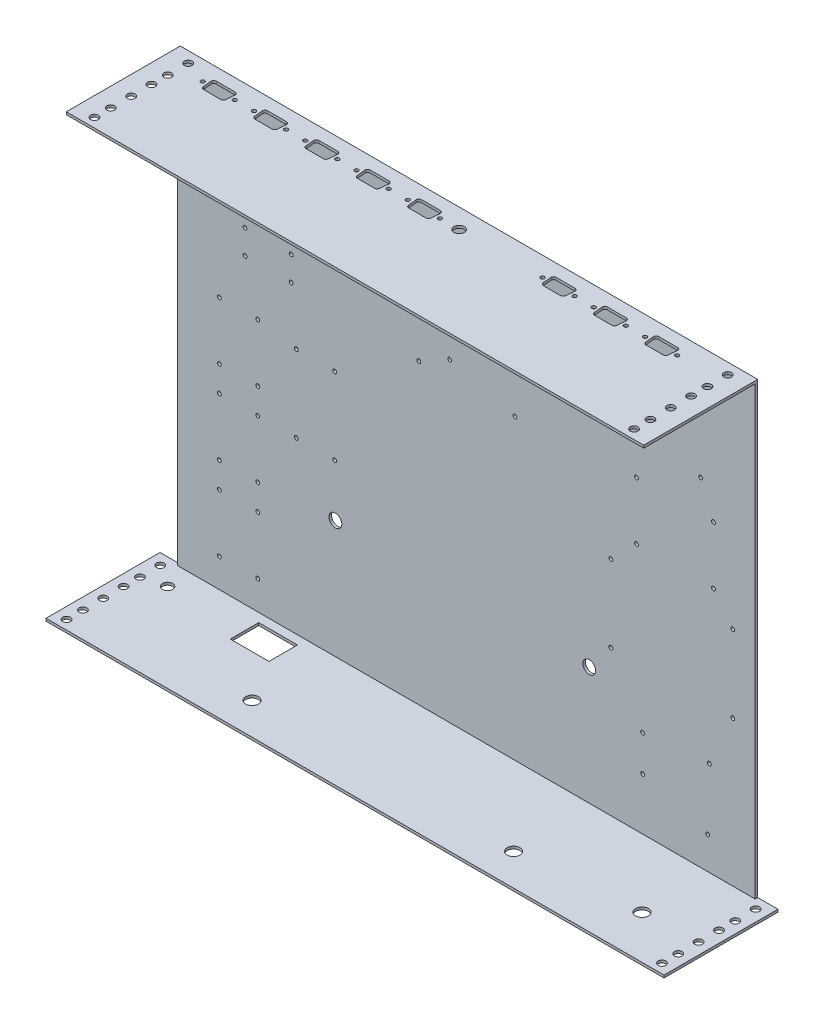
from build123d import *

# Parameters (mm, degrees)
SKETCH1_W           = 450.4
SKETCH1_H           = 352
BOSS_EXTRUDE1_DEPTH = 2
SKETCH4_W           = 482
SKETCH4_H           = 88.9
SKETCH4_W_2         = 9.5
SKETCH4_H_2         = 9.5
BOSS_EXTRUDE4_DEPTH = 2
CUT_EXTRUDE2_REACH  = 354
SKETCH5_W           = 15.8
SKETCH5_H           = 88.9
CUT_EXTRUDE3_REACH  = 354
SKETCH6_W           = 9.5
SKETCH6_H           = 9.5
CUT_EXTRUDE4_REACH  = 4
SKETCH9_R           = 5
CUT_EXTRUDE5_REACH  = 354
SKETCH11_R          = 5
SKETCH12_R          = 1.5
CUT_EXTRUDE6_DEPTH  = 30
SKETCH15_R          = 1.499345427
SKETCH15_R_2        = 1.5
CUT_EXTRUDE7_DEPTH  = 2
SKETCH16_R          = 1.5
SKETCH16_R_2        = 4
CUT_EXTRUDE9_DEPTH  = 2
CUT_EXTRUDE10_REACH = 354
SKETCH17_R          = 4
SKETCH17_R_2        = 5
SKETCH17_W          = 30.2
SKETCH17_H          = 22.2
SKETCH18_W          = 9.5
SKETCH18_H          = 9.5
SKETCH18_R          = 3
BOSS_EXTRUDE5_DEPTH = 2
SKETCH20_W          = 9.5
SKETCH20_H          = 9.5
SKETCH20_R          = 3
BOSS_EXTRUDE6_DEPTH = 2


with BuildPart() as part:
    # Sketch1 → Boss-Extrude1 (new body)
    with BuildSketch(Plane.XY):
        Rectangle(SKETCH1_W, SKETCH1_H)
    extrude(amount=BOSS_EXTRUDE1_DEPTH)

    # Sketch4 → Boss-Extrude4 (add)
    with BuildSketch(Plane.XZ.offset(176)):
        with Locations((0, 44.45)):
            Rectangle(SKETCH4_W, SKETCH4_H)
        with Locations((-232.2, 68.95)):
            Rectangle(SKETCH4_W_2, SKETCH4_H_2, mode=Mode.SUBTRACT)
        with Locations((-232.2, 81.65)):
            Rectangle(SKETCH4_W_2, SKETCH4_H_2, mode=Mode.SUBTRACT)
        with Locations((232.2, 68.95)):
            Rectangle(SKETCH4_W_2, SKETCH4_H_2, mode=Mode.SUBTRACT)
        with Locations((232.2, 81.65)):
            Rectangle(SKETCH4_W_2, SKETCH4_H_2, mode=Mode.SUBTRACT)
        with Locations((-232.2, 53.07)):
            Rectangle(SKETCH4_W_2, SKETCH4_H_2, mode=Mode.SUBTRACT)
        with Locations((232.2, 53.07)):
            Rectangle(SKETCH4_W_2, SKETCH4_H_2, mode=Mode.SUBTRACT)
        with Locations((-232.2, 37.19)):
            Rectangle(SKETCH4_W_2, SKETCH4_H_2, mode=Mode.SUBTRACT)
        with Locations((-232.2, 24.49)):
            Rectangle(SKETCH4_W_2, SKETCH4_H_2, mode=Mode.SUBTRACT)
        with Locations((-232.2, 8.61)):
            Rectangle(SKETCH4_W_2, SKETCH4_H_2, mode=Mode.SUBTRACT)
        with Locations((232.2, 37.19)):
            Rectangle(SKETCH4_W_2, SKETCH4_H_2, mode=Mode.SUBTRACT)
        with Locations((232.2, 24.49)):
            Rectangle(SKETCH4_W_2, SKETCH4_H_2, mode=Mode.SUBTRACT)
        with Locations((232.2, 8.61)):
            Rectangle(SKETCH4_W_2, SKETCH4_H_2, mode=Mode.SUBTRACT)
    boss_extrude4 = extrude(amount=-BOSS_EXTRUDE4_DEPTH)

    # Mirror1: Boss-Extrude4 across plane
    add(boss_extrude4.mirror(Plane.ZX))

    # Sketch5 → Cut-Extrude2 (cut, up to next)
    with BuildSketch(Plane(origin=(0, 176, 0), x_dir=(1, 0, 0), z_dir=(0, 1, 0)), mode=Mode.PRIVATE) as cut_extrude2_sk1:
        with Locations((-233.1, -44.45)):
            Rectangle(SKETCH5_W, SKETCH5_H)
    cut_extrude2_tool1 = extrude(cut_extrude2_sk1.sketch, amount=-CUT_EXTRUDE2_REACH, mode=Mode.PRIVATE) & part.part
    add(cut_extrude2_tool1.solids().sort_by_distance((-233.1, 176, 44.45))[0], mode=Mode.SUBTRACT)
    # Sketch5 → Cut-Extrude2 (cut, up to next)
    with BuildSketch(Plane(origin=(0, 176, 0), x_dir=(1, 0, 0), z_dir=(0, 1, 0)), mode=Mode.PRIVATE) as cut_extrude2_sk2:
        with Locations((233.1, -44.45)):
            Rectangle(SKETCH5_W, SKETCH5_H)
    cut_extrude2_tool2 = extrude(cut_extrude2_sk2.sketch, amount=-CUT_EXTRUDE2_REACH, mode=Mode.PRIVATE) & part.part
    add(cut_extrude2_tool2.solids().sort_by_distance((233.1, 176, 44.45))[0], mode=Mode.SUBTRACT)

    # Sketch6 → Cut-Extrude3 (cut, up to next)
    with BuildSketch(Plane(origin=(0, 176, 0), x_dir=(1, 0, 0), z_dir=(0, 1, 0)), mode=Mode.PRIVATE) as cut_extrude3_sk1:
        with Locations((-210.45, -8.61)):
            Rectangle(SKETCH6_W, SKETCH6_H)
    cut_extrude3_tool1 = extrude(cut_extrude3_sk1.sketch, amount=-CUT_EXTRUDE3_REACH, mode=Mode.PRIVATE) & part.part
    add(cut_extrude3_tool1.solids().sort_by_distance((-210.45, 176, 8.61))[0], mode=Mode.SUBTRACT)
    # Sketch6 → Cut-Extrude3 (cut, up to next)
    with BuildSketch(Plane(origin=(0, 176, 0), x_dir=(1, 0, 0), z_dir=(0, 1, 0)), mode=Mode.PRIVATE) as cut_extrude3_sk2:
        with Locations((-210.45, -24.49)):
            Rectangle(SKETCH6_W, SKETCH6_H)
    cut_extrude3_tool2 = extrude(cut_extrude3_sk2.sketch, amount=-CUT_EXTRUDE3_REACH, mode=Mode.PRIVATE) & part.part
    add(cut_extrude3_tool2.solids().sort_by_distance((-210.45, 176, 24.49))[0], mode=Mode.SUBTRACT)
    # Sketch6 → Cut-Extrude3 (cut, up to next)
    with BuildSketch(Plane(origin=(0, 176, 0), x_dir=(1, 0, 0), z_dir=(0, 1, 0)), mode=Mode.PRIVATE) as cut_extrude3_sk3:
        with Locations((210.45, -8.61)):
            Rectangle(SKETCH6_W, SKETCH6_H)
    cut_extrude3_tool3 = extrude(cut_extrude3_sk3.sketch, amount=-CUT_EXTRUDE3_REACH, mode=Mode.PRIVATE) & part.part
    add(cut_extrude3_tool3.solids().sort_by_distance((210.45, 176, 8.61))[0], mode=Mode.SUBTRACT)
    # Sketch6 → Cut-Extrude3 (cut, up to next)
    with BuildSketch(Plane(origin=(0, 176, 0), x_dir=(1, 0, 0), z_dir=(0, 1, 0)), mode=Mode.PRIVATE) as cut_extrude3_sk4:
        with Locations((210.45, -24.49)):
            Rectangle(SKETCH6_W, SKETCH6_H)
    cut_extrude3_tool4 = extrude(cut_extrude3_sk4.sketch, amount=-CUT_EXTRUDE3_REACH, mode=Mode.PRIVATE) & part.part
    add(cut_extrude3_tool4.solids().sort_by_distance((210.45, 176, 24.49))[0], mode=Mode.SUBTRACT)
    # Sketch6 → Cut-Extrude3 (cut, up to next)
    with BuildSketch(Plane(origin=(0, 176, 0), x_dir=(1, 0, 0), z_dir=(0, 1, 0)), mode=Mode.PRIVATE) as cut_extrude3_sk5:
        with Locations((-210.45, -81.65)):
            Rectangle(SKETCH6_W, SKETCH6_H)
    cut_extrude3_tool5 = extrude(cut_extrude3_sk5.sketch, amount=-CUT_EXTRUDE3_REACH, mode=Mode.PRIVATE) & part.part
    add(cut_extrude3_tool5.solids().sort_by_distance((-210.45, 176, 81.65))[0], mode=Mode.SUBTRACT)
    # Sketch6 → Cut-Extrude3 (cut, up to next)
    with BuildSketch(Plane(origin=(0, 176, 0), x_dir=(1, 0, 0), z_dir=(0, 1, 0)), mode=Mode.PRIVATE) as cut_extrude3_sk6:
        with Locations((-210.45, -37.19)):
            Rectangle(SKETCH6_W, SKETCH6_H)
    cut_extrude3_tool6 = extrude(cut_extrude3_sk6.sketch, amount=-CUT_EXTRUDE3_REACH, mode=Mode.PRIVATE) & part.part
    add(cut_extrude3_tool6.solids().sort_by_distance((-210.45, 176, 37.19))[0], mode=Mode.SUBTRACT)
    # Sketch6 → Cut-Extrude3 (cut, up to next)
    with BuildSketch(Plane(origin=(0, 176, 0), x_dir=(1, 0, 0), z_dir=(0, 1, 0)), mode=Mode.PRIVATE) as cut_extrude3_sk7:
        with Locations((210.45, -37.19)):
            Rectangle(SKETCH6_W, SKETCH6_H)
    cut_extrude3_tool7 = extrude(cut_extrude3_sk7.sketch, amount=-CUT_EXTRUDE3_REACH, mode=Mode.PRIVATE) & part.part
    add(cut_extrude3_tool7.solids().sort_by_distance((210.45, 176, 37.19))[0], mode=Mode.SUBTRACT)
    # Sketch6 → Cut-Extrude3 (cut, up to next)
    with BuildSketch(Plane(origin=(0, 176, 0), x_dir=(1, 0, 0), z_dir=(0, 1, 0)), mode=Mode.PRIVATE) as cut_extrude3_sk8:
        with Locations((-210.45, -68.95)):
            Rectangle(SKETCH6_W, SKETCH6_H)
    cut_extrude3_tool8 = extrude(cut_extrude3_sk8.sketch, amount=-CUT_EXTRUDE3_REACH, mode=Mode.PRIVATE) & part.part
    add(cut_extrude3_tool8.solids().sort_by_distance((-210.45, 176, 68.95))[0], mode=Mode.SUBTRACT)
    # Sketch6 → Cut-Extrude3 (cut, up to next)
    with BuildSketch(Plane(origin=(0, 176, 0), x_dir=(1, 0, 0), z_dir=(0, 1, 0)), mode=Mode.PRIVATE) as cut_extrude3_sk9:
        with Locations((-210.45, -53.07)):
            Rectangle(SKETCH6_W, SKETCH6_H)
    cut_extrude3_tool9 = extrude(cut_extrude3_sk9.sketch, amount=-CUT_EXTRUDE3_REACH, mode=Mode.PRIVATE) & part.part
    add(cut_extrude3_tool9.solids().sort_by_distance((-210.45, 176, 53.07))[0], mode=Mode.SUBTRACT)
    # Sketch6 → Cut-Extrude3 (cut, up to next)
    with BuildSketch(Plane(origin=(0, 176, 0), x_dir=(1, 0, 0), z_dir=(0, 1, 0)), mode=Mode.PRIVATE) as cut_extrude3_sk10:
        with Locations((210.45, -53.07)):
            Rectangle(SKETCH6_W, SKETCH6_H)
    cut_extrude3_tool10 = extrude(cut_extrude3_sk10.sketch, amount=-CUT_EXTRUDE3_REACH, mode=Mode.PRIVATE) & part.part
    add(cut_extrude3_tool10.solids().sort_by_distance((210.45, 176, 53.07))[0], mode=Mode.SUBTRACT)
    # Sketch6 → Cut-Extrude3 (cut, up to next)
    with BuildSketch(Plane(origin=(0, 176, 0), x_dir=(1, 0, 0), z_dir=(0, 1, 0)), mode=Mode.PRIVATE) as cut_extrude3_sk11:
        with Locations((210.45, -68.95)):
            Rectangle(SKETCH6_W, SKETCH6_H)
    cut_extrude3_tool11 = extrude(cut_extrude3_sk11.sketch, amount=-CUT_EXTRUDE3_REACH, mode=Mode.PRIVATE) & part.part
    add(cut_extrude3_tool11.solids().sort_by_distance((210.45, 176, 68.95))[0], mode=Mode.SUBTRACT)
    # Sketch6 → Cut-Extrude3 (cut, up to next)
    with BuildSketch(Plane(origin=(0, 176, 0), x_dir=(1, 0, 0), z_dir=(0, 1, 0)), mode=Mode.PRIVATE) as cut_extrude3_sk12:
        with Locations((210.45, -81.65)):
            Rectangle(SKETCH6_W, SKETCH6_H)
    cut_extrude3_tool12 = extrude(cut_extrude3_sk12.sketch, amount=-CUT_EXTRUDE3_REACH, mode=Mode.PRIVATE) & part.part
    add(cut_extrude3_tool12.solids().sort_by_distance((210.45, 176, 81.65))[0], mode=Mode.SUBTRACT)

    # Sketch9 → Cut-Extrude4 (cut, up to next)
    with BuildSketch(Plane.XY.offset(2), mode=Mode.PRIVATE) as cut_extrude4_sk1:
        with Locations((-102.2, -82)):
            Circle(SKETCH9_R)
    cut_extrude4_tool1 = extrude(cut_extrude4_sk1.sketch, amount=-CUT_EXTRUDE4_REACH, mode=Mode.PRIVATE) & part.part
    add(cut_extrude4_tool1.solids().sort_by_distance((-102.2, -82, 2))[0], mode=Mode.SUBTRACT)
    # Sketch9 → Cut-Extrude4 (cut, up to next)
    with BuildSketch(Plane.XY.offset(2), mode=Mode.PRIVATE) as cut_extrude4_sk2:
        with Locations((95.8, -82)):
            Circle(SKETCH9_R)
    cut_extrude4_tool2 = extrude(cut_extrude4_sk2.sketch, amount=-CUT_EXTRUDE4_REACH, mode=Mode.PRIVATE) & part.part
    add(cut_extrude4_tool2.solids().sort_by_distance((95.8, -82, 2))[0], mode=Mode.SUBTRACT)

    # Sketch11 → Cut-Extrude5 (cut, up to next)
    with BuildSketch(Plane.XZ.offset(176), mode=Mode.PRIVATE) as cut_extrude5_sk1:
        with Locations((-105.2, 64)):
            Circle(SKETCH11_R)
    cut_extrude5_tool1 = extrude(cut_extrude5_sk1.sketch, amount=-CUT_EXTRUDE5_REACH, mode=Mode.PRIVATE) & part.part
    add(cut_extrude5_tool1.solids().sort_by_distance((-105.2, -176, 64))[0], mode=Mode.SUBTRACT)
    # Sketch11 → Cut-Extrude5 (cut, up to next)
    with BuildSketch(Plane.XZ.offset(176), mode=Mode.PRIVATE) as cut_extrude5_sk2:
        with Locations((98.8, 64)):
            Circle(SKETCH11_R)
    cut_extrude5_tool2 = extrude(cut_extrude5_sk2.sketch, amount=-CUT_EXTRUDE5_REACH, mode=Mode.PRIVATE) & part.part
    add(cut_extrude5_tool2.solids().sort_by_distance((98.8, -176, 64))[0], mode=Mode.SUBTRACT)

    # Sketch12 → Cut-Extrude6 (cut)
    with BuildSketch(Plane.XY.offset(2)):
        with Locations((-192.7, -151.5)):
            Circle(SKETCH12_R)
        with Locations((-162.7, -151.5)):
            Circle(SKETCH12_R)
        with Locations((-192.7, -86.5)):
            Circle(SKETCH12_R)
        with Locations((-162.7, -86.5)):
            Circle(SKETCH12_R)
        with Locations((-192.7, -41.5)):
            Circle(SKETCH12_R)
        with Locations((-162.7, -41.5)):
            Circle(SKETCH12_R)
        with Locations((-192.7, -21.5)):
            Circle(SKETCH12_R)
        with Locations((-192.7, -106.5)):
            Circle(SKETCH12_R)
        with Locations((-162.7, -106.5)):
            Circle(SKETCH12_R)
        with Locations((-162.7, -21.5)):
            Circle(SKETCH12_R)
        with Locations((-132.7, -41.5)):
            Circle(SKETCH12_R)
        with Locations((-102.7, -41.5)):
            Circle(SKETCH12_R)
        with Locations((-132.7, 18.5)):
            Circle(SKETCH12_R)
        with Locations((-102.7, 18.5)):
            Circle(SKETCH12_R)
        with Locations((-162.7, 23.5)):
            Circle(SKETCH12_R)
        with Locations((-192.7, 23.5)):
            Circle(SKETCH12_R)
    extrude(amount=-CUT_EXTRUDE6_DEPTH, mode=Mode.SUBTRACT)

    # Sketch15 → Cut-Extrude7 (cut)
    with BuildSketch(Plane.XY.offset(2)):
        with Locations((-172.7, 80.5)):
            Circle(SKETCH15_R)
        with Locations((-172.7, 61.5)):
            Circle(SKETCH15_R_2)
        with Locations((-136.7, 61.5)):
            Circle(SKETCH15_R_2)
        with Locations((-136.7, 80.5)):
            Circle(SKETCH15_R_2)
        with Locations((112.7, -0.5)):
            Circle(SKETCH15_R_2)
        with Locations((112.7, -60.5)):
            Circle(SKETCH15_R_2)
        with Locations((207.7, -60.5)):
            Circle(SKETCH15_R_2)
        with Locations((207.7, -0.5)):
            Circle(SKETCH15_R_2)
        with Locations((132.7, 64.5)):
            Circle(SKETCH15_R_2)
        with Locations((132.7, 19.5)):
            Circle(SKETCH15_R_2)
        with Locations((192.7, 19.5)):
            Circle(SKETCH15_R_2)
        with Locations((192.7, 64.5)):
            Circle(SKETCH15_R_2)
        with Locations((92.7, 136.5)):
            Circle(SKETCH15_R_2)
        with Locations((92.7, 89.5)):
            Circle(SKETCH15_R_2)
        with Locations((182.7, 89.5)):
            Circle(SKETCH15_R_2)
        with Locations((182.7, 136.5)):
            Circle(SKETCH15_R_2)
        with Locations((39.08, 106.761)):
            Circle(SKETCH15_R_2)
        with Locations((-43.398, 106.761)):
            Circle(SKETCH15_R_2)
        with Locations((-37.145, 58.239)):
            Circle(SKETCH15_R_2)
        with Locations((37.81, 58.239)):
            Circle(SKETCH15_R_2)
        with Locations((-12.95, 99.144)):
            Circle(SKETCH15_R_2)
        with Locations((-12.95, 71.235)):
            Circle(SKETCH15_R_2)
        with Locations((189.48, -100.389)):
            Circle(SKETCH15_R_2)
        with Locations((188.215, -148.911)):
            Circle(SKETCH15_R_2)
        with Locations((137.45, -105.467)):
            Circle(SKETCH15_R_2)
        with Locations((137.45, -133.376)):
            Circle(SKETCH15_R_2)
    extrude(amount=-CUT_EXTRUDE7_DEPTH, mode=Mode.SUBTRACT)

    # Sketch16 → Cut-Extrude9 (cut)
    with BuildSketch(Plane(origin=(0, 176, 0), x_dir=(1, 0, 0), z_dir=(0, 1, 0))):
        with Locations((-152.502278756, -15.187845189)):
            Circle(SKETCH16_R)
        with Locations((-127.497721244, -15.187845189)):
            Circle(SKETCH16_R)
        with Locations((-112.497721244, -15.187845189)):
            Circle(SKETCH16_R)
        with Locations((-87.493163733, -15.187845189)):
            Circle(SKETCH16_R)
        with Locations((-72.493163733, -15.187845189)):
            Circle(SKETCH16_R)
        with Locations((-47.488606221, -15.187845189)):
            Circle(SKETCH16_R)
        with Locations((-32.488606221, -15.187845189)):
            Circle(SKETCH16_R)
        with Locations((-7.48404871, -15.187845189)):
            Circle(SKETCH16_R)
        with Locations((7.51595129, -15.187845189)):
            Circle(SKETCH16_R_2)
        with Locations((-192.506836267, -15.187845189)):
            Circle(SKETCH16_R)
        with Locations((-167.502278756, -15.187845189)):
            Circle(SKETCH16_R)
        with Locations((97.511393779, -15.187845189)):
            Circle(SKETCH16_R)
        with Locations((72.506836267, -15.187845189)):
            Circle(SKETCH16_R)
        with Locations((112.511393779, -15.187845189)):
            Circle(SKETCH16_R)
        with Locations((137.51595129, -15.187845189)):
            Circle(SKETCH16_R)
        with Locations((152.51595129, -15.187845189)):
            Circle(SKETCH16_R)
        with Locations((177.520508802, -15.187845189)):
            Circle(SKETCH16_R)
        with BuildLine():
            Line((-147.352440505, -9.7), (-132.647559495, -9.7))
            ThreePointArc((-132.647559495, -9.7), (-131.168422859, -10.353837004), (-130.65640049, -11.887845189))
            Line((-130.65640049, -11.887845189), (-131.279041999, -18.487845189))
            ThreePointArc((-131.279041999, -18.487845189), (-131.924038009, -19.779136636), (-133.270201004, -20.3))
            Line((-133.270201004, -20.3), (-146.729798996, -20.3))
            ThreePointArc((-146.729798996, -20.3), (-148.075961991, -19.779136636), (-148.720958001, -18.487845189))
            Line((-148.720958001, -18.487845189), (-149.34359951, -11.887845189))
            ThreePointArc((-149.34359951, -11.887845189), (-148.831577141, -10.353837004), (-147.352440505, -9.7))
        make_face()
        with BuildLine():
            Line((-107.347882994, -9.7), (-92.643001984, -9.7))
            ThreePointArc((-92.643001984, -9.7), (-91.163865347, -10.353837004), (-90.651842978, -11.887845189))
            Line((-90.651842978, -11.887845189), (-91.274484488, -18.487845189))
            ThreePointArc((-91.274484488, -18.487845189), (-91.919480497, -19.779136636), (-93.265643493, -20.3))
            Line((-93.265643493, -20.3), (-106.725241484, -20.3))
            ThreePointArc((-106.725241484, -20.3), (-108.07140448, -19.779136636), (-108.71640049, -18.487845189))
            Line((-108.71640049, -18.487845189), (-109.339041999, -11.887845189))
            ThreePointArc((-109.339041999, -11.887845189), (-108.82701963, -10.353837004), (-107.347882994, -9.7))
        make_face()
        with BuildLine():
            Line((-67.343325482, -9.7), (-52.638444472, -9.7))
            ThreePointArc((-52.638444472, -9.7), (-51.159307836, -10.353837004), (-50.647285467, -11.887845189))
            Line((-50.647285467, -11.887845189), (-51.269926976, -18.487845189))
            ThreePointArc((-51.269926976, -18.487845189), (-51.914922986, -19.779136636), (-53.261085981, -20.3))
            Line((-53.261085981, -20.3), (-66.720683973, -20.3))
            ThreePointArc((-66.720683973, -20.3), (-68.066846968, -19.779136636), (-68.711842978, -18.487845189))
            Line((-68.711842978, -18.487845189), (-69.334484488, -11.887845189))
            ThreePointArc((-69.334484488, -11.887845189), (-68.822462118, -10.353837004), (-67.343325482, -9.7))
        make_face()
        with BuildLine():
            Line((-27.338767971, -9.7), (-12.633886961, -9.7))
            ThreePointArc((-12.633886961, -9.7), (-11.154750324, -10.353837004), (-10.642727955, -11.887845189))
            Line((-10.642727955, -11.887845189), (-11.265369465, -18.487845189))
            ThreePointArc((-11.265369465, -18.487845189), (-11.910365474, -19.779136636), (-13.25652847, -20.3))
            Line((-13.25652847, -20.3), (-26.716126461, -20.3))
            ThreePointArc((-26.716126461, -20.3), (-28.062289457, -19.779136636), (-28.707285467, -18.487845189))
            Line((-28.707285467, -18.487845189), (-29.329926976, -11.887845189))
            ThreePointArc((-29.329926976, -11.887845189), (-28.817904607, -10.353837004), (-27.338767971, -9.7))
        make_face()
        with BuildLine():
            Line((-187.356998016, -9.7), (-172.652117006, -9.7))
            ThreePointArc((-172.652117006, -9.7), (-171.17298037, -10.353837004), (-170.660958001, -11.887845189))
            Line((-170.660958001, -11.887845189), (-171.28359951, -18.487845189))
            ThreePointArc((-171.28359951, -18.487845189), (-171.92859552, -19.779136636), (-173.274758516, -20.3))
            Line((-173.274758516, -20.3), (-186.734356507, -20.3))
            ThreePointArc((-186.734356507, -20.3), (-188.080519503, -19.779136636), (-188.725515512, -18.487845189))
            Line((-188.725515512, -18.487845189), (-189.348157022, -11.887845189))
            ThreePointArc((-189.348157022, -11.887845189), (-188.836134653, -10.353837004), (-187.356998016, -9.7))
        make_face()
        with BuildLine():
            Line((78.279316027, -20.3), (91.738914019, -20.3))
            ThreePointArc((91.738914019, -20.3), (93.085077014, -19.779136636), (93.730073024, -18.487845189))
            Line((93.730073024, -18.487845189), (94.352714533, -11.887845189))
            ThreePointArc((94.352714533, -11.887845189), (93.840692164, -10.353837004), (92.361555528, -9.7))
            Line((92.361555528, -9.7), (77.656674518, -9.7))
            ThreePointArc((77.656674518, -9.7), (76.177537882, -10.353837004), (75.665515512, -11.887845189))
            Line((75.665515512, -11.887845189), (76.288157022, -18.487845189))
            ThreePointArc((76.288157022, -18.487845189), (76.933153032, -19.779136636), (78.279316027, -20.3))
        make_face()
        with BuildLine():
            Line((118.283873539, -20.3), (131.74347153, -20.3))
            ThreePointArc((131.74347153, -20.3), (133.089634526, -19.779136636), (133.734630535, -18.487845189))
            Line((133.734630535, -18.487845189), (134.357272045, -11.887845189))
            ThreePointArc((134.357272045, -11.887845189), (133.845249676, -10.353837004), (132.366113039, -9.7))
            Line((132.366113039, -9.7), (117.661232029, -9.7))
            ThreePointArc((117.661232029, -9.7), (116.182095393, -10.353837004), (115.670073024, -11.887845189))
            Line((115.670073024, -11.887845189), (116.292714533, -18.487845189))
            ThreePointArc((116.292714533, -18.487845189), (116.937710543, -19.779136636), (118.283873539, -20.3))
        make_face()
        with BuildLine():
            Line((158.28843105, -20.3), (171.748029041, -20.3))
            ThreePointArc((171.748029041, -20.3), (173.094192037, -19.779136636), (173.739188047, -18.487845189))
            Line((173.739188047, -18.487845189), (174.361829556, -11.887845189))
            ThreePointArc((174.361829556, -11.887845189), (173.849807187, -10.353837004), (172.370670551, -9.7))
            Line((172.370670551, -9.7), (157.665789541, -9.7))
            ThreePointArc((157.665789541, -9.7), (156.186652904, -10.353837004), (155.674630535, -11.887845189))
            Line((155.674630535, -11.887845189), (156.297272045, -18.487845189))
            ThreePointArc((156.297272045, -18.487845189), (156.942268055, -19.779136636), (158.28843105, -20.3))
        make_face()
    extrude(amount=-CUT_EXTRUDE9_DEPTH, mode=Mode.SUBTRACT)

    # Sketch17 → Cut-Extrude10 (cut, up to next)
    with BuildSketch(Plane.XZ.offset(176), mode=Mode.PRIVATE) as cut_extrude10_sk1:
        with Locations((-215.1, 20)):
            Circle(SKETCH17_R)
    cut_extrude10_tool1 = extrude(cut_extrude10_sk1.sketch, amount=-CUT_EXTRUDE10_REACH, mode=Mode.PRIVATE) & part.part
    add(cut_extrude10_tool1.solids().sort_by_distance((-215.1, -176, 20))[0], mode=Mode.SUBTRACT)
    # Sketch17 → Cut-Extrude10 (cut, up to next)
    with BuildSketch(Plane.XZ.offset(176), mode=Mode.PRIVATE) as cut_extrude10_sk2:
        with Locations((190, 55)):
            Circle(SKETCH17_R_2)
    cut_extrude10_tool2 = extrude(cut_extrude10_sk2.sketch, amount=-CUT_EXTRUDE10_REACH, mode=Mode.PRIVATE) & part.part
    add(cut_extrude10_tool2.solids().sort_by_distance((190, -176, 55))[0], mode=Mode.SUBTRACT)
    # Sketch17 → Cut-Extrude10 (cut, up to next)
    with BuildSketch(Plane.XZ.offset(176), mode=Mode.PRIVATE) as cut_extrude10_sk3:
        with Locations((-140, 20)):
            Rectangle(SKETCH17_W, SKETCH17_H)
    cut_extrude10_tool3 = extrude(cut_extrude10_sk3.sketch, amount=-CUT_EXTRUDE10_REACH, mode=Mode.PRIVATE) & part.part
    add(cut_extrude10_tool3.solids().sort_by_distance((-140, -176, 20))[0], mode=Mode.SUBTRACT)

    # Sketch18 → Boss-Extrude5 (add)
    with BuildSketch(Plane.XZ.offset(176)):
        with Locations((-232.2, 68.95)):
            Rectangle(SKETCH18_W, SKETCH18_H)
        with Locations((-232.2, 68.95)):
            Circle(SKETCH18_R, mode=Mode.SUBTRACT)
        with Locations((-232.2, 81.65)):
            Rectangle(SKETCH18_W, SKETCH18_H)
        with Locations((-232.2, 81.65)):
            Circle(SKETCH18_R, mode=Mode.SUBTRACT)
        with Locations((-232.2, 53.07)):
            Rectangle(SKETCH18_W, SKETCH18_H)
        with Locations((-232.2, 53.07)):
            Circle(SKETCH18_R, mode=Mode.SUBTRACT)
        with Locations((-232.2, 37.19)):
            Rectangle(SKETCH18_W, SKETCH18_H)
        with Locations((-232.2, 37.19)):
            Circle(SKETCH18_R, mode=Mode.SUBTRACT)
        with Locations((-232.2, 24.49)):
            Rectangle(SKETCH18_W, SKETCH18_H)
        with Locations((-232.2, 24.49)):
            Circle(SKETCH18_R, mode=Mode.SUBTRACT)
        with Locations((-232.2, 8.61)):
            Rectangle(SKETCH18_W, SKETCH18_H)
        with Locations((-232.2, 8.61)):
            Circle(SKETCH18_R, mode=Mode.SUBTRACT)
        with Locations((232.2, 68.95)):
            Rectangle(SKETCH18_W, SKETCH18_H)
        with Locations((232.2, 68.95)):
            Circle(SKETCH18_R, mode=Mode.SUBTRACT)
        with Locations((232.2, 81.65)):
            Rectangle(SKETCH18_W, SKETCH18_H)
        with Locations((232.2, 81.65)):
            Circle(SKETCH18_R, mode=Mode.SUBTRACT)
        with Locations((232.2, 53.07)):
            Rectangle(SKETCH18_W, SKETCH18_H)
        with Locations((232.2, 53.07)):
            Circle(SKETCH18_R, mode=Mode.SUBTRACT)
        with Locations((232.2, 37.19)):
            Rectangle(SKETCH18_W, SKETCH18_H)
        with Locations((232.2, 37.19)):
            Circle(SKETCH18_R, mode=Mode.SUBTRACT)
        with Locations((232.2, 24.49)):
            Rectangle(SKETCH18_W, SKETCH18_H)
        with Locations((232.2, 24.49)):
            Circle(SKETCH18_R, mode=Mode.SUBTRACT)
        with Locations((232.2, 8.61)):
            Rectangle(SKETCH18_W, SKETCH18_H)
        with Locations((232.2, 8.61)):
            Circle(SKETCH18_R, mode=Mode.SUBTRACT)
    extrude(amount=-BOSS_EXTRUDE5_DEPTH)

    # Sketch20 → Boss-Extrude6 (add)
    with BuildSketch(Plane(origin=(0, 176, 0), x_dir=(1, 0, 0), z_dir=(0, 1, 0))):
        with Locations((210.45, -24.49)):
            Rectangle(SKETCH20_W, SKETCH20_H)
        with Locations((210.45, -24.49)):
            Circle(SKETCH20_R, mode=Mode.SUBTRACT)
        with Locations((210.45, -8.61)):
            Rectangle(SKETCH20_W, SKETCH20_H)
        with Locations((210.45, -8.61)):
            Circle(SKETCH20_R, mode=Mode.SUBTRACT)
        with Locations((210.45, -37.19)):
            Rectangle(SKETCH20_W, SKETCH20_H)
        with Locations((210.45, -37.19)):
            Circle(SKETCH20_R, mode=Mode.SUBTRACT)
        with Locations((210.45, -53.07)):
            Rectangle(SKETCH20_W, SKETCH20_H)
        with Locations((210.45, -53.07)):
            Circle(SKETCH20_R, mode=Mode.SUBTRACT)
        with Locations((210.45, -68.95)):
            Rectangle(SKETCH20_W, SKETCH20_H)
        with Locations((210.45, -68.95)):
            Circle(SKETCH20_R, mode=Mode.SUBTRACT)
        with Locations((210.45, -81.65)):
            Rectangle(SKETCH20_W, SKETCH20_H)
        with Locations((210.45, -81.65)):
            Circle(SKETCH20_R, mode=Mode.SUBTRACT)
        with Locations((-210.45, -81.65)):
            Rectangle(SKETCH20_W, SKETCH20_H)
        with Locations((-210.45, -81.65)):
            Circle(SKETCH20_R, mode=Mode.SUBTRACT)
        with Locations((-210.45, -68.95)):
            Rectangle(SKETCH20_W, SKETCH20_H)
        with Locations((-210.45, -68.95)):
            Circle(SKETCH20_R, mode=Mode.SUBTRACT)
        with Locations((-210.45, -53.07)):
            Rectangle(SKETCH20_W, SKETCH20_H)
        with Locations((-210.45, -53.07)):
            Circle(SKETCH20_R, mode=Mode.SUBTRACT)
        with Locations((-210.45, -37.19)):
            Rectangle(SKETCH20_W, SKETCH20_H)
        with Locations((-210.45, -37.19)):
            Circle(SKETCH20_R, mode=Mode.SUBTRACT)
        with Locations((-210.45, -24.49)):
            Rectangle(SKETCH20_W, SKETCH20_H)
        with Locations((-210.45, -24.49)):
            Circle(SKETCH20_R, mode=Mode.SUBTRACT)
        with Locations((-210.45, -8.61)):
            Rectangle(SKETCH20_W, SKETCH20_H)
        with Locations((-210.45, -8.61)):
            Circle(SKETCH20_R, mode=Mode.SUBTRACT)
    extrude(amount=-BOSS_EXTRUDE6_DEPTH)


solid = part.part
